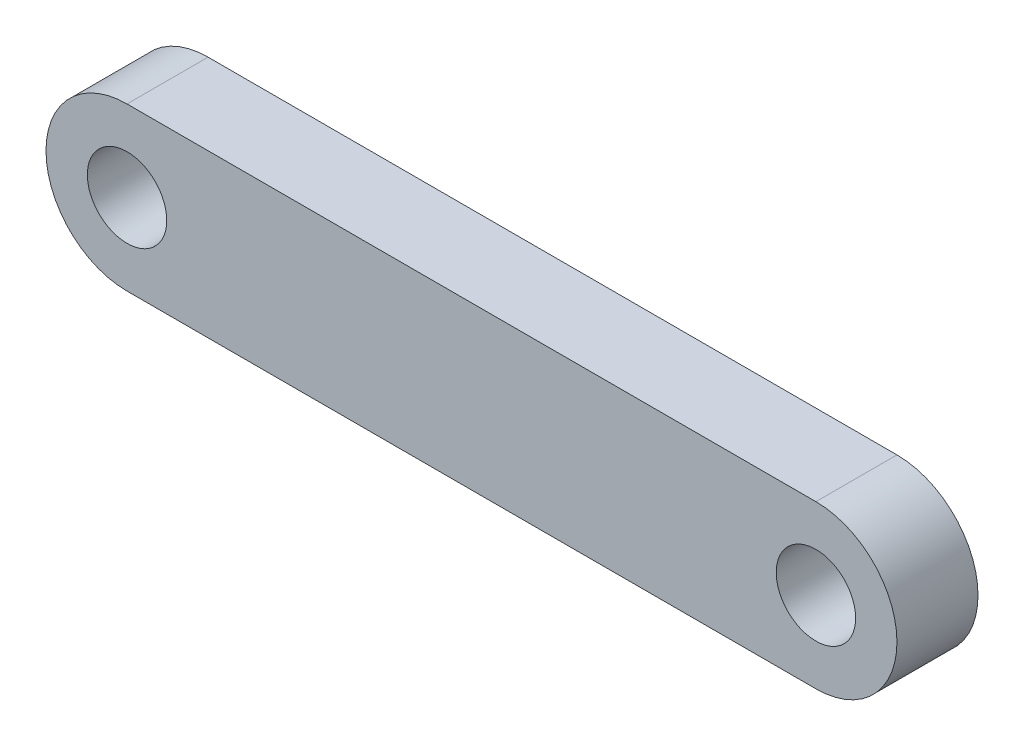
from build123d import *

# Parameters (mm, degrees)
SKETCH2_R           = 3.1115
BOSS_EXTRUDE1_DEPTH = 3.175


with BuildPart() as part:
    # Sketch2 → Boss-Extrude1 (new body, symmetric)
    with BuildSketch(Plane.XY):
        with BuildLine():
            Line((-26.9875, 6.35), (26.9875, 6.35))
            ThreePointArc((26.9875, 6.35), (33.3375, 0), (26.9875, -6.35))
            Line((26.9875, -6.35), (-26.9875, -6.35))
            ThreePointArc((-26.9875, -6.35), (-33.3375, 0), (-26.9875, 6.35))
        make_face()
        with Locations((-26.9875, 0)):
            Circle(SKETCH2_R, mode=Mode.SUBTRACT)
        with Locations((26.9875, 0)):
            Circle(SKETCH2_R, mode=Mode.SUBTRACT)
    extrude(amount=BOSS_EXTRUDE1_DEPTH, both=True)


solid = part.part
